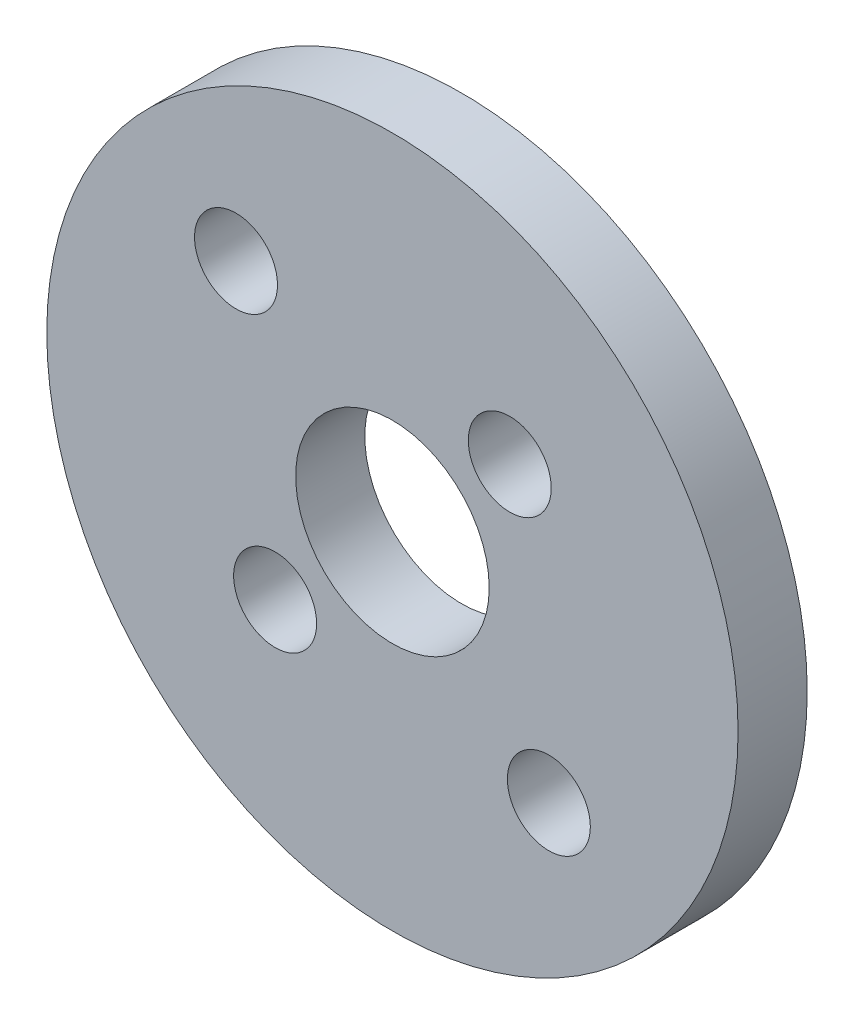
from build123d import *

# Parameters (mm, degrees)
SKETCH1_R           = 12.5
SKETCH1_R_2         = 1.5
SKETCH1_R_3         = 3.5
BOSS_EXTRUDE1_DEPTH = 2.5


with BuildPart() as part:
    # Sketch1 → Boss-Extrude1 (new body)
    with BuildSketch(Plane.XY):
        with Locations((0, -150)):
            Circle(SKETCH1_R)
        with Locations((5.656854249, -155.656854249)):
            Circle(SKETCH1_R_2, mode=Mode.SUBTRACT)
        with Locations((4.242640687, -145.757359313)):
            Circle(SKETCH1_R_2, mode=Mode.SUBTRACT)
        with Locations((-5.656854249, -144.343145751)):
            Circle(SKETCH1_R_2, mode=Mode.SUBTRACT)
        with Locations((-4.242640687, -154.242640687)):
            Circle(SKETCH1_R_2, mode=Mode.SUBTRACT)
        with Locations((0, -150)):
            Circle(SKETCH1_R_3, mode=Mode.SUBTRACT)
    extrude(amount=BOSS_EXTRUDE1_DEPTH)


solid = part.part
